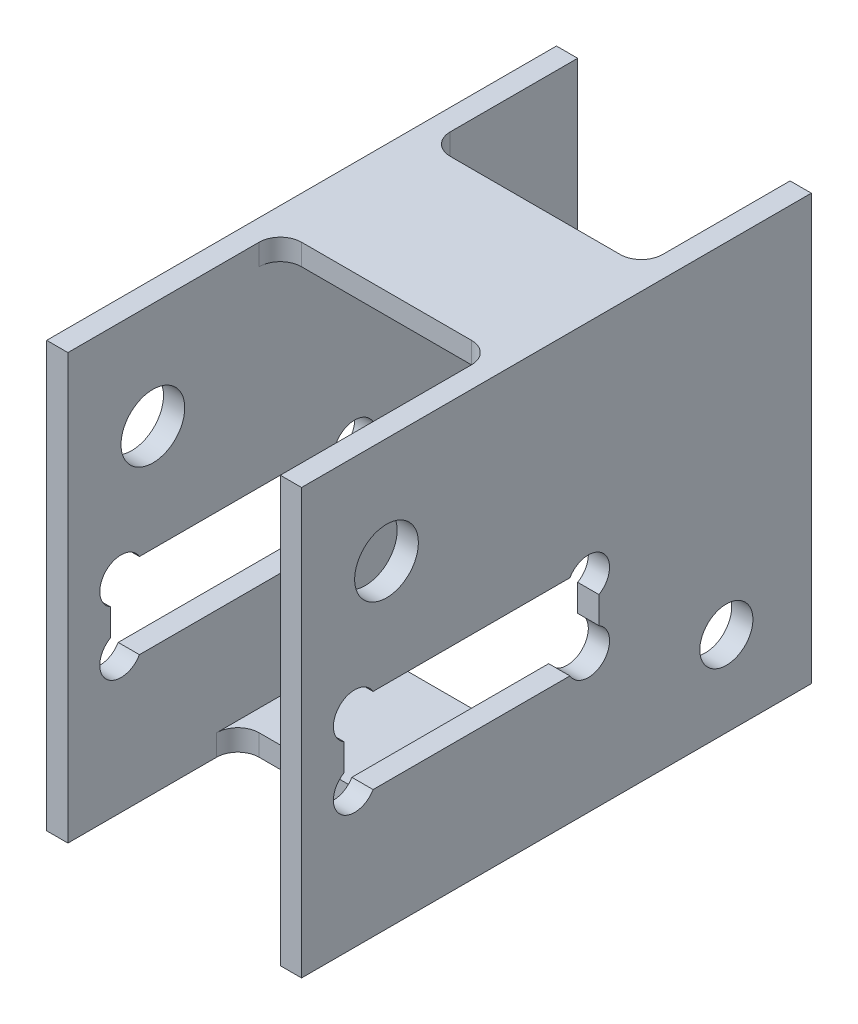
from build123d import *

# Parameters (mm, degrees)
SKETCH1_W           = 38.1
SKETCH1_H           = 63.5
SKETCH1_W_2         = 31.75
SKETCH1_H_2         = 57.15
BOSS_EXTRUDE1_DEPTH = 76.2
SKETCH2_R           = 3.175
SKETCH2_W           = 38.1
SKETCH2_H           = 12.7
SKETCH2_R_2         = 4.7625
SKETCH2_R_3         = 3.96875
CUT_EXTRUDE1_DEPTH  = 39.1
CUT_EXTRUDE2_REACH  = 65.5
SKETCH3_W           = 31.75
SKETCH3_H           = 31.75
SKETCH3_H_2         = 22.225
CUT_EXTRUDE3_REACH  = 65.5
SKETCH4_W           = 31.75
SKETCH4_H           = 31.75
SKETCH4_H_2         = 25.4
FILLET1_R           = 3.175


with BuildPart() as part:
    # Sketch1 → Boss-Extrude1 (new body)
    with BuildSketch(Plane.XY):
        Rectangle(SKETCH1_W, SKETCH1_H)
        Rectangle(SKETCH1_W_2, SKETCH1_H_2, mode=Mode.SUBTRACT)
    extrude(amount=BOSS_EXTRUDE1_DEPTH)

    # Sketch2 → Cut-Extrude1 (cut, through all)
    with BuildSketch(Plane(origin=(19.05, 0, 0), x_dir=(0, 0, -1), z_dir=(1, 0, 0))):
        with Locations((-33.3375, -1.5875)):
            Circle(SKETCH2_R)
        with Locations((-68.2625, -1.5875)):
            Circle(SKETCH2_R)
        with Locations((-68.2625, -11.1125)):
            Circle(SKETCH2_R)
        with Locations((-33.3375, -11.1125)):
            Circle(SKETCH2_R)
        with Locations((-50.8, -6.35)):
            Rectangle(SKETCH2_W, SKETCH2_H)
        with BuildLine():
            ThreePointArc((-65.512869343, 0), (-70.50756403, 0.65756403), (-69.85, -4.337130657))
            Line((-69.85, -4.337130657), (-69.85, 0))
            Line((-69.85, 0), (-65.512869343, 0))
        make_face()
        with BuildLine():
            Line((-69.85, 0), (-69.85, -4.337130657))
            ThreePointArc((-69.85, -4.337130657), (-66.675, -4.337130657), (-65.0875, -1.5875))
            ThreePointArc((-65.0875, -1.5875), (-65.195685502, -0.765749532), (-65.512869343, 0))
            Line((-65.512869343, 0), (-69.85, 0))
        make_face()
        with BuildLine():
            ThreePointArc((-36.087130657, 0), (-35.58256403, -3.83256403), (-31.75, -4.337130657))
            Line((-31.75, -4.337130657), (-31.75, 0))
            Line((-31.75, 0), (-36.087130657, 0))
        make_face()
        with BuildLine():
            Line((-31.75, 0), (-31.75, -4.337130657))
            ThreePointArc((-31.75, -4.337130657), (-30.587869343, -3.175), (-30.1625, -1.5875))
            ThreePointArc((-30.1625, -1.5875), (-32.515749532, 1.479314498), (-36.087130657, 0))
            Line((-36.087130657, 0), (-31.75, 0))
        make_face()
        with BuildLine():
            ThreePointArc((-31.75, -8.362869343), (-35.58256403, -8.86743597), (-36.087130657, -12.7))
            Line((-36.087130657, -12.7), (-31.75, -12.7))
            Line((-31.75, -12.7), (-31.75, -8.362869343))
        make_face()
        with BuildLine():
            Line((-31.75, -12.7), (-36.087130657, -12.7))
            ThreePointArc((-36.087130657, -12.7), (-32.515749532, -14.179314498), (-30.1625, -11.1125))
            ThreePointArc((-30.1625, -11.1125), (-30.587869343, -9.525), (-31.75, -8.362869343))
            Line((-31.75, -8.362869343), (-31.75, -12.7))
        make_face()
        with BuildLine():
            Line((-69.85, -8.362869343), (-69.85, -12.7))
            Line((-69.85, -12.7), (-65.512869343, -12.7))
            ThreePointArc((-65.512869343, -12.7), (-65.195685502, -11.934250468), (-65.0875, -11.1125))
            ThreePointArc((-65.0875, -11.1125), (-66.675, -8.362869343), (-69.85, -8.362869343))
        make_face()
        with BuildLine():
            Line((-65.512869343, -12.7), (-69.85, -12.7))
            Line((-69.85, -12.7), (-69.85, -8.362869343))
            ThreePointArc((-69.85, -8.362869343), (-70.50756403, -13.35756403), (-65.512869343, -12.7))
        make_face()
        with Locations((-63.5, 15.875)):
            Circle(SKETCH2_R_2)
        with Locations((-12.7, -19.05)):
            Circle(SKETCH2_R_3)
    extrude(amount=-CUT_EXTRUDE1_DEPTH, mode=Mode.SUBTRACT)

    # Sketch3 → Cut-Extrude2 (cut, up to next)
    with BuildSketch(Plane(origin=(0, 31.75, 0), x_dir=(1, 0, 0), z_dir=(0, 1, 0)), mode=Mode.PRIVATE) as cut_extrude2_sk1:
        with Locations((0, -60.325)):
            Rectangle(SKETCH3_W, SKETCH3_H)
    cut_extrude2_tool1 = extrude(cut_extrude2_sk1.sketch, amount=-CUT_EXTRUDE2_REACH, mode=Mode.PRIVATE) & part.part
    add(cut_extrude2_tool1.solids().sort_by_distance((0, 31.75, 60.325))[0], mode=Mode.SUBTRACT)
    # Sketch3 → Cut-Extrude2 (cut, up to next)
    with BuildSketch(Plane(origin=(0, 31.75, 0), x_dir=(1, 0, 0), z_dir=(0, 1, 0)), mode=Mode.PRIVATE) as cut_extrude2_sk2:
        with Locations((0, -11.1125)):
            Rectangle(SKETCH3_W, SKETCH3_H_2)
    cut_extrude2_tool2 = extrude(cut_extrude2_sk2.sketch, amount=-CUT_EXTRUDE2_REACH, mode=Mode.PRIVATE) & part.part
    add(cut_extrude2_tool2.solids().sort_by_distance((0, 31.75, 11.1125))[0], mode=Mode.SUBTRACT)

    # Sketch4 → Cut-Extrude3 (cut, up to next)
    with BuildSketch(Plane.XZ.offset(31.75), mode=Mode.PRIVATE) as cut_extrude3_sk1:
        with Locations((0, 15.875)):
            Rectangle(SKETCH4_W, SKETCH4_H)
    cut_extrude3_tool1 = extrude(cut_extrude3_sk1.sketch, amount=-CUT_EXTRUDE3_REACH, mode=Mode.PRIVATE) & part.part
    add(cut_extrude3_tool1.solids().sort_by_distance((0, -31.75, 15.875))[0], mode=Mode.SUBTRACT)
    # Sketch4 → Cut-Extrude3 (cut, up to next)
    with BuildSketch(Plane.XZ.offset(31.75), mode=Mode.PRIVATE) as cut_extrude3_sk2:
        with Locations((0, 63.5)):
            Rectangle(SKETCH4_W, SKETCH4_H_2)
    cut_extrude3_tool2 = extrude(cut_extrude3_sk2.sketch, amount=-CUT_EXTRUDE3_REACH, mode=Mode.PRIVATE) & part.part
    add(cut_extrude3_tool2.solids().sort_by_distance((0, -31.75, 63.5))[0], mode=Mode.SUBTRACT)

    # Fillet1
    fillet1_edges = [part.edges().sort_by_distance(p)[0] for p in [
        (15.875, 30.1625, 44.45),
        (-15.875, 30.1625, 44.45),
        (15.875, 30.1625, 22.225),
        (-15.875, 30.1625, 22.225),
        (-15.875, -30.1625, 31.75),
        (15.875, -30.1625, 31.75),
        (-15.875, -30.1625, 50.8),
        (15.875, -30.1625, 50.8),
    ]]
    fillet(fillet1_edges, radius=FILLET1_R)


solid = part.part
